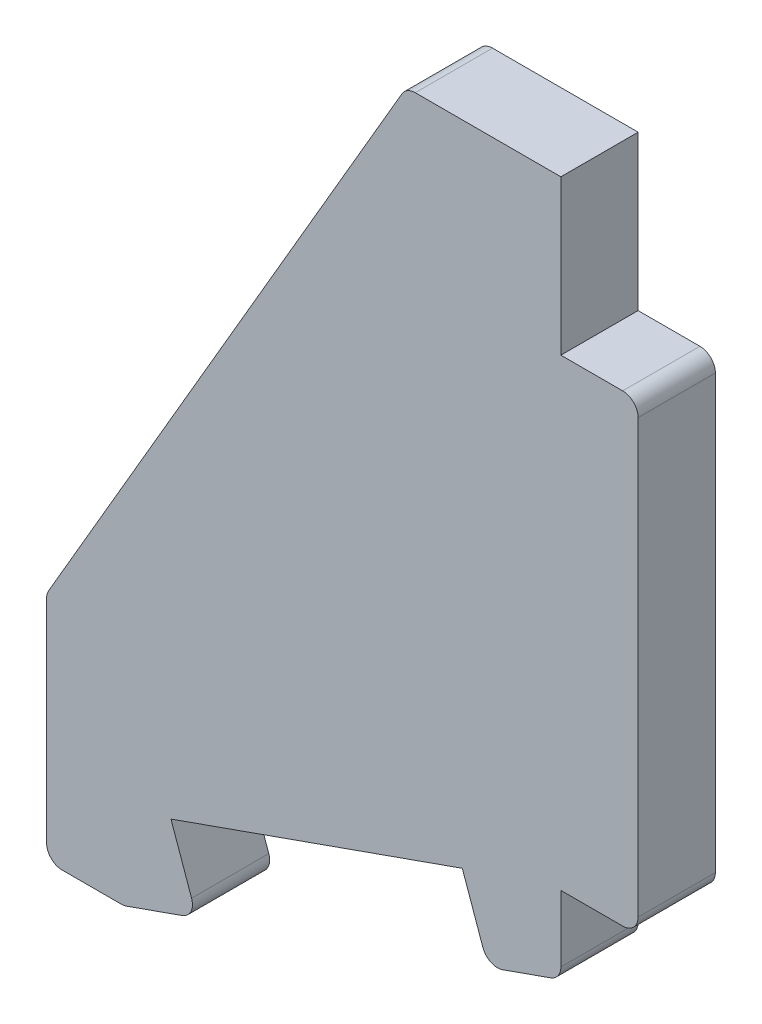
from build123d import *

# Parameters (mm, degrees)
BOSS_EXTRUDE1_DEPTH = 5
FILLET1_R           = 1


with BuildPart() as part:
    # Sketch1 → Boss-Extrude1 (new body)
    with BuildSketch(Plane.XY):
        Polygon((33.284271247, 15), (33.284271247, 45), (28.284271247, 45), (28.284271247, 55), (18.284271247, 55), (-5, 15), (-5, 0), (0, 0), (4.714045208, 1.666666667), (3.047378541, 6.380711875), (21.903559373, 13.047378541), (23.57022604, 8.333333333), (28.284271247, 10), (28.284271247, 15), align=None)
    extrude(amount=BOSS_EXTRUDE1_DEPTH)

    # Fillet1
    fillet1_edges = [part.edges().sort_by_distance(p)[0] for p in [
        (0, 0, 2.5),
        (-5, 0, 2.5),
        (-5, 15, 2.5),
        (18.284271247, 55, 2.5),
        (33.284271247, 45, 2.5),
        (33.284271247, 15, 2.5),
        (28.284271247, 10, 2.5),
        (23.57022604, 8.333333333, 2.5),
        (4.714045208, 1.666666667, 2.5),
    ]]
    fillet(fillet1_edges, radius=FILLET1_R)


solid = part.part
